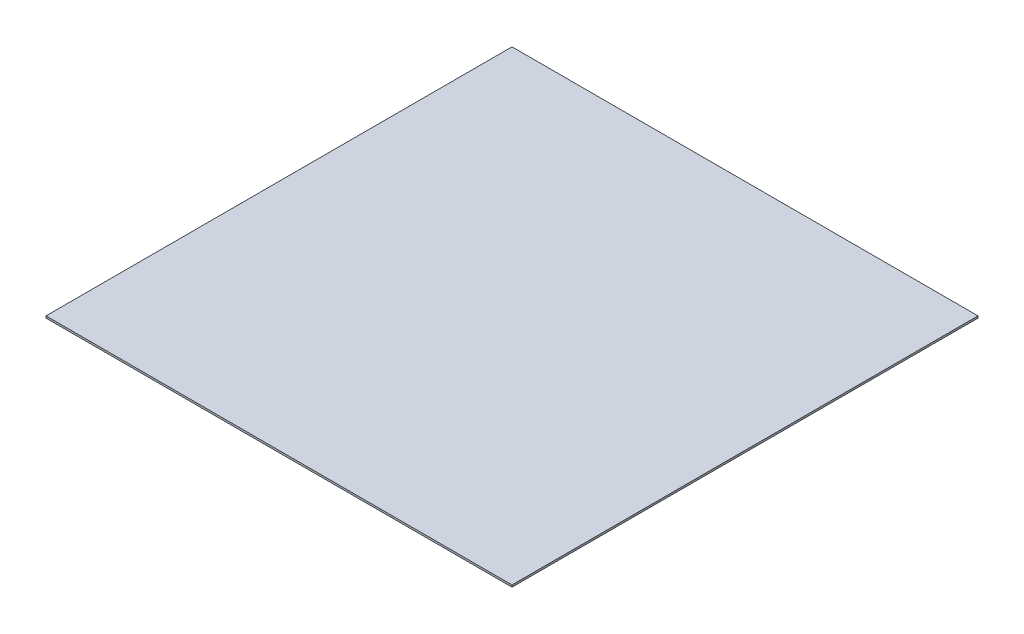
from build123d import *

# Parameters (mm, degrees)
SKETCH1_W           = 1524
SKETCH1_H           = 1524
BOSS_EXTRUDE1_DEPTH = 3.175


with BuildPart() as part:
    # Sketch1 → Boss-Extrude1 (new body, symmetric)
    with BuildSketch(Plane(origin=(0, 0, 0), x_dir=(1, 0, 0), z_dir=(0, 1, 0))):
        Rectangle(SKETCH1_W, SKETCH1_H)
    extrude(amount=BOSS_EXTRUDE1_DEPTH, both=True)


solid = part.part
